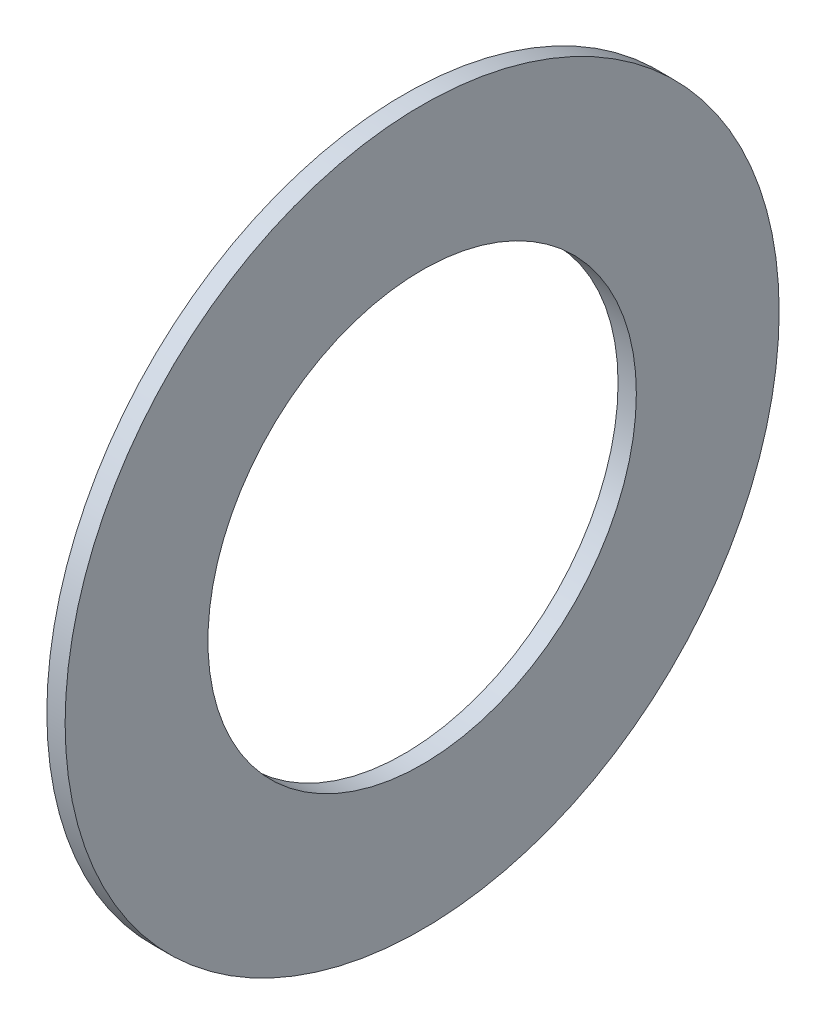
from build123d import *

# Parameters (mm, degrees)
SKETCH1_R      = 15.875
SKETCH1_R_2    = 9.525
EXTRUDE1_DEPTH = 0.8128


with BuildPart() as part:
    # Sketch1 → Extrude1 (new body)
    with BuildSketch(Plane(origin=(0, 0, 0), x_dir=(0, 0, -1), z_dir=(1, 0, 0))):
        Circle(SKETCH1_R)
        Circle(SKETCH1_R_2, mode=Mode.SUBTRACT)
    extrude(amount=EXTRUDE1_DEPTH)


solid = part.part
